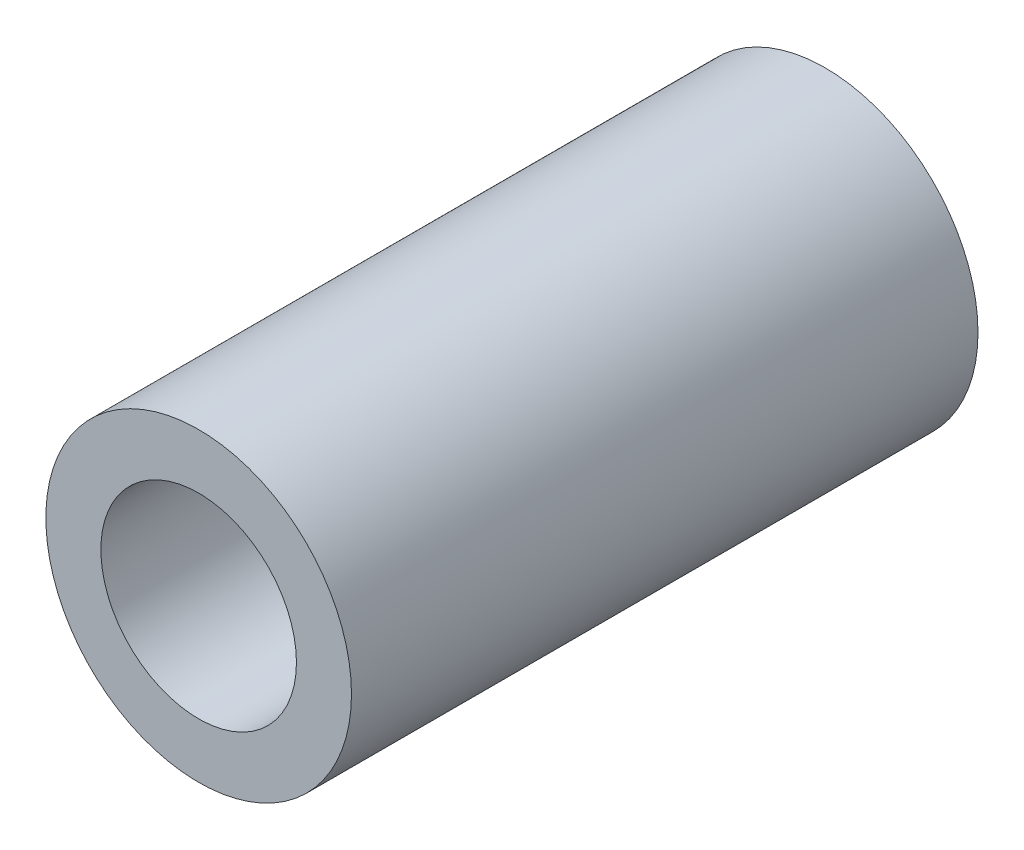
from build123d import *

# Parameters (mm, degrees)
SKETCH_1_R      = 5
SKETCH_1_R_2    = 3.2
EXTRUDE_1_DEPTH = 20.5


with BuildPart() as part:
    # 草图1 → 凸台-拉伸1 (new body)
    with BuildSketch(Plane.XY):
        Circle(SKETCH_1_R)
        Circle(SKETCH_1_R_2, mode=Mode.SUBTRACT)
    extrude(amount=EXTRUDE_1_DEPTH)


solid = part.part
